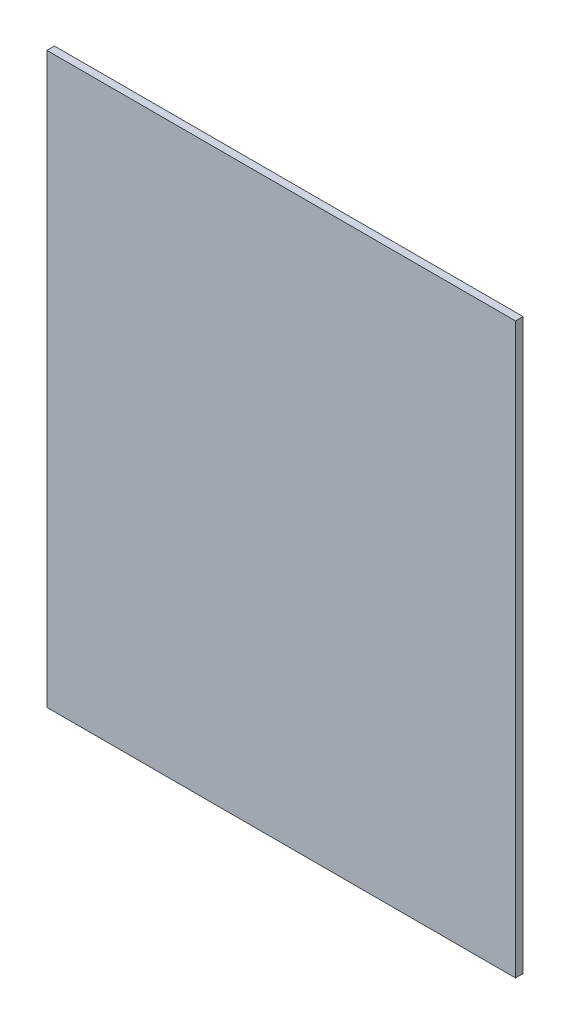
from build123d import *

# Parameters (mm, degrees)
SKETCH1_W           = 196.85
SKETCH1_H           = 239
BOSS_EXTRUDE1_DEPTH = 3.175


with BuildPart() as part:
    # Sketch1 → Boss-Extrude1 (new body)
    with BuildSketch(Plane.XY):
        Rectangle(SKETCH1_W, SKETCH1_H)
    extrude(amount=BOSS_EXTRUDE1_DEPTH)


solid = part.part
